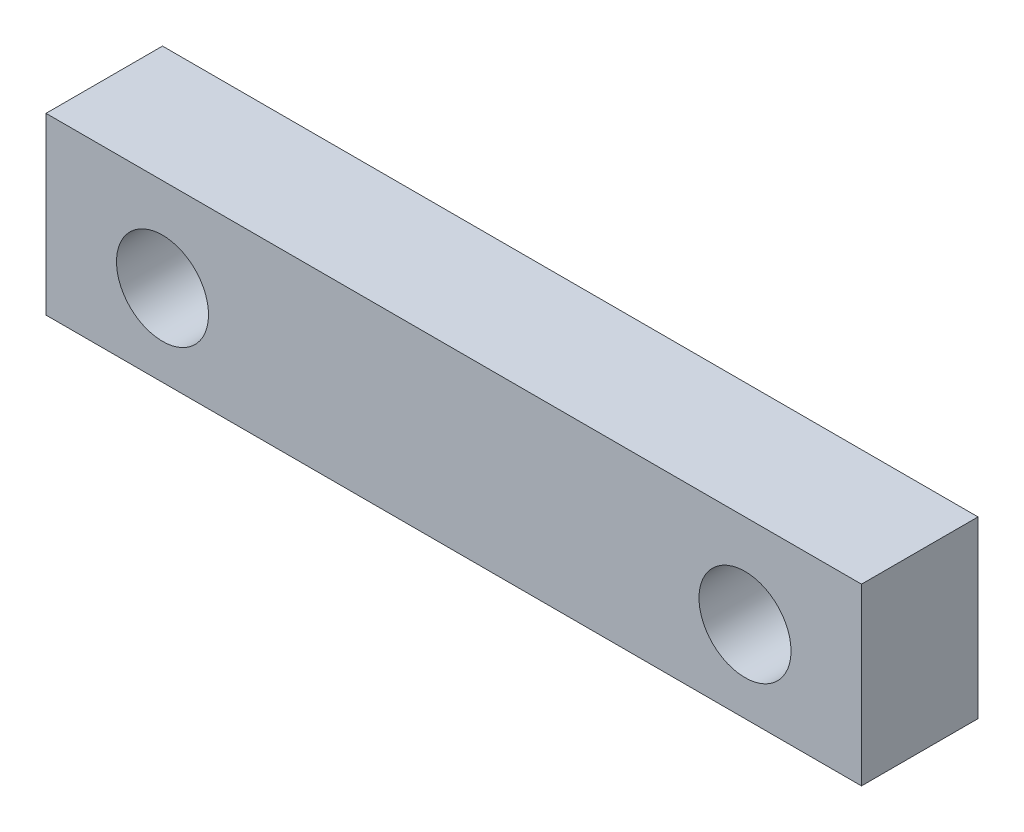
from build123d import *

# Parameters (mm, degrees)
SKETCH_1_W      = 44.45
SKETCH_1_H      = 9.525
SKETCH_1_R      = 2.50825
EXTRUDE_1_DEPTH = 6.35


with BuildPart() as part:
    # Эскиз1 → Бобышка-Вытянуть1 (new body)
    with BuildSketch(Plane.XY):
        with Locations((-124.578833131, 53.243233664)):
            Rectangle(SKETCH_1_W, SKETCH_1_H)
        with Locations((-108.703833131, 52.925733664)):
            Circle(SKETCH_1_R, mode=Mode.SUBTRACT)
        with Locations((-140.453833131, 52.925733664)):
            Circle(SKETCH_1_R, mode=Mode.SUBTRACT)
    extrude(amount=EXTRUDE_1_DEPTH)


solid = part.part
